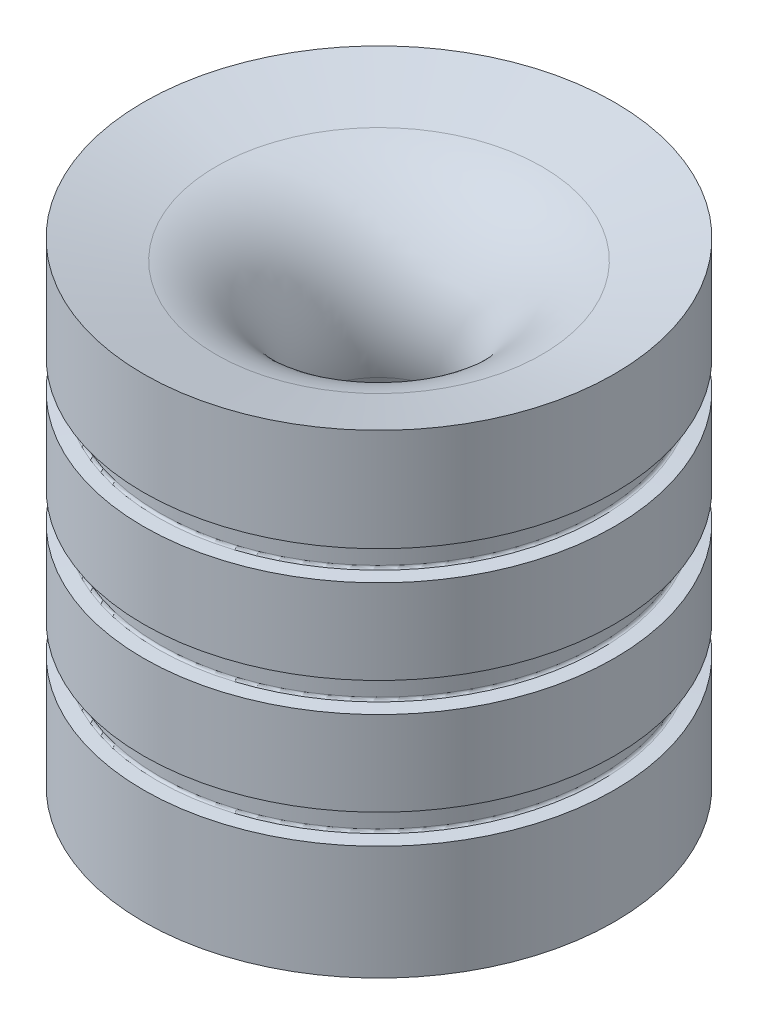
from build123d import *

# Parameters (mm, degrees)
LPATTERN1_COUNT = 3
LPATTERN1_PITCH = 20


with BuildPart() as part:
    # Sketch1 → Revolve1 (revolve)
    with BuildSketch(Plane.XY):
        with BuildLine():
            Line((41.275, 83.162331026), (41.275, 0))
            Line((41.275, 0), (27.15, 0))
            Line((27.15, 0), (12.999631822, 52.809892987))
            ThreePointArc((12.999631822, 52.809892987), (15.197441117, 69.50391198), (28.555981008, 79.754280158))
            Line((28.555981008, 79.754280158), (41.275, 83.162331026))
        make_face()
    revolve(axis=Axis((0, 11.203886574, 0), (0, 1, 0)))

    # Sketch3 → Groove for AS 568-234, O-Ring1 (revolve, cut)
    with BuildSketch(Plane(origin=(0, 11.203886574, 0), x_dir=(0, 0, -1), z_dir=(-1, 0, 0))):
        with BuildLine():
            Line((38.861359272, -9.01505737), (41.3639, -8.796113426))
            Line((41.3639, -8.796113426), (41.3639, -13.983801313))
            Line((41.3639, -13.983801313), (38.861359272, -13.76485737))
            ThreePointArc((38.861359272, -13.76485737), (38.572380224, -13.622348674), (38.4556, -13.322048826))
            Line((38.4556, -13.322048826), (38.4556, -9.457865913))
            ThreePointArc((38.4556, -9.457865913), (38.572380224, -9.157566066), (38.861359272, -9.01505737))
        make_face()
    groove_for_as_568_234_o_ring1 = revolve(axis=Axis((0, -38.796113426, 0), (0, 1, 0)), mode=Mode.SUBTRACT)

    # LPattern1: Groove for AS 568-234, O-Ring1 ×3
    with Locations(*[(0, i * LPATTERN1_PITCH, 0) for i in range(1, LPATTERN1_COUNT)]):
        add(groove_for_as_568_234_o_ring1, mode=Mode.SUBTRACT)


solid = part.part
